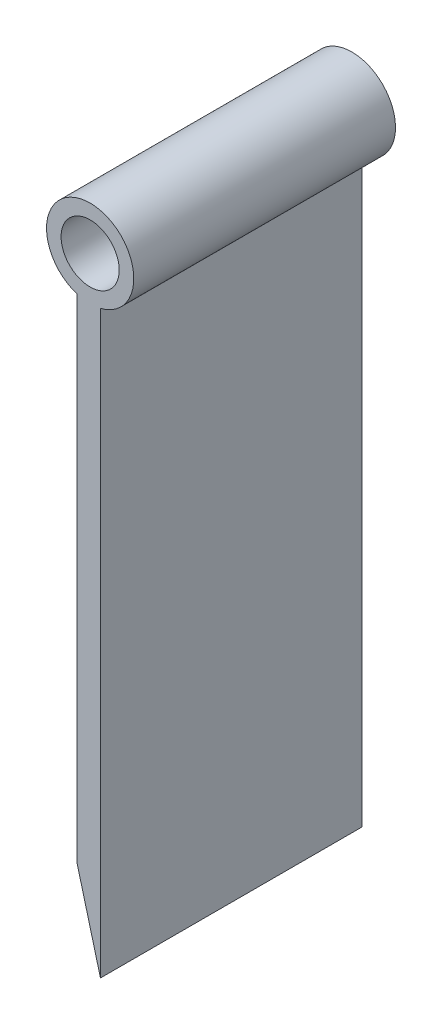
from build123d import *

# Parameters (mm, degrees)
CROQUIS1_R              = 2.5
SALIENTE_EXTRUIR2_DEPTH = 22.5


with BuildPart() as part:
    # Croquis1 → Saliente-Extruir2 (new body)
    with BuildSketch(Plane.XY):
        with BuildLine():
            Line((0, 0), (0, 49.8562756))
            ThreePointArc((0, 49.8562756), (-0.768605016, 57.248148258), (-2, 49.919150955))
            Line((-2, 49.919150955), (-2, 7.5))
            Line((-2, 7.5), (0, 0))
        make_face()
        with Locations((-0.886438093, 53.5)):
            Circle(CROQUIS1_R, mode=Mode.SUBTRACT)
    extrude(amount=SALIENTE_EXTRUIR2_DEPTH)


solid = part.part
